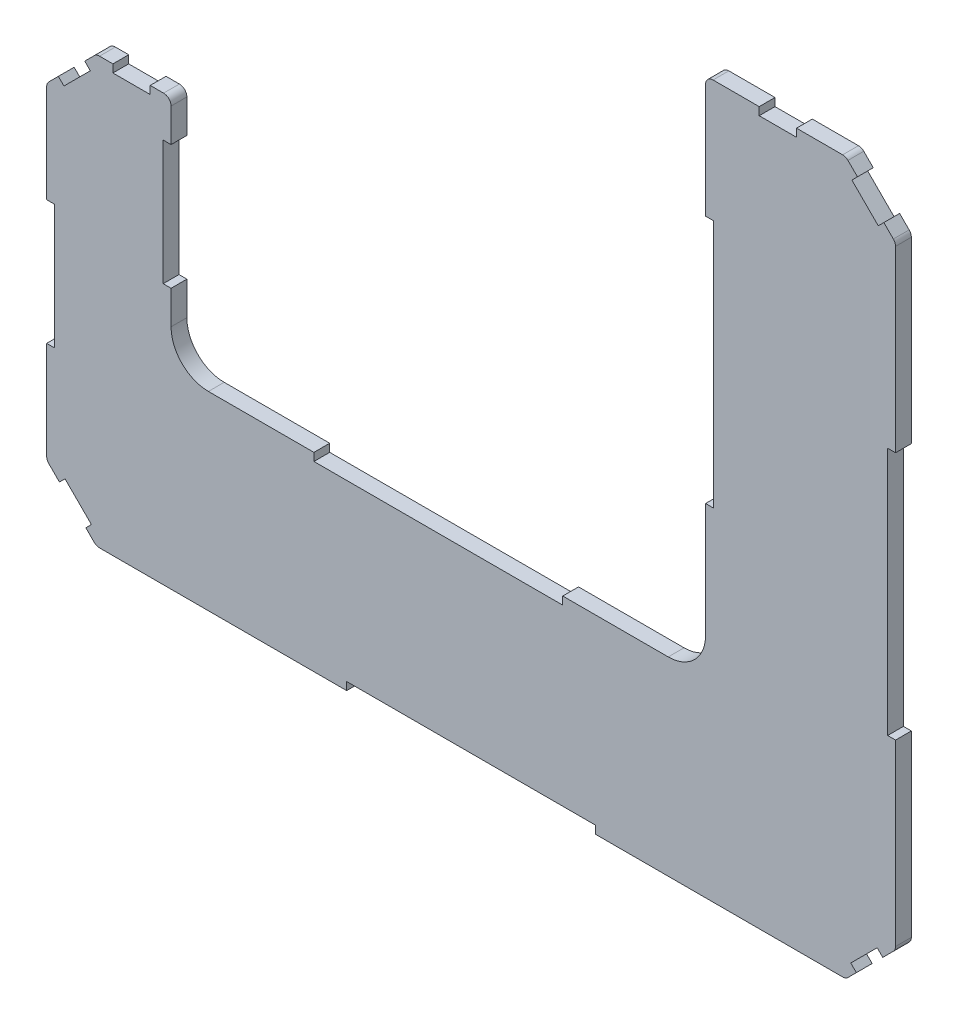
from build123d import *

# Parameters (mm, degrees)
BOSS_EXTRUDE1_DEPTH      = 3.175
BOSS_EXTRUDE1_DEPTH_BACK = 3.175
CHAMFER1_SIZE            = 20
FILLET1_R                = 15
FILLET2_R                = 3
SKETCH4_W                = 3.175
SKETCH4_H                = 50
SKETCH4_W_2              = 15
SKETCH4_H_2              = 3.175
SKETCH4_W_3              = 100
SKETCH4_H_3              = 100
WALL_SLOTS_DEPTH         = 60
FILLET3_R                = 3


with BuildPart() as part:
    # Sketch2 → Boss-Extrude1 (new body, two sides)
    with BuildSketch(Plane.XY) as boss_extrude1_sk:
        Polygon((-157.4125, 94.825), (-107.4125, 94.825), (-107.4125, 0), (107.4125, 0), (107.4125, 209.825), (183.7625, 209.825), (183.7625, -76.35), (58.275, -76.35), (-31.925, -76.35), (-157.4125, -76.35), align=None)
    extrude(amount=BOSS_EXTRUDE1_DEPTH)
    extrude(boss_extrude1_sk.sketch, amount=-BOSS_EXTRUDE1_DEPTH_BACK)

    # Chamfer1
    chamfer1_edges = [part.edges().sort_by_distance(p)[0] for p in [
        (-157.4125, 94.825, 0),
        (183.7625, 209.825, 0),
        (183.7625, -76.35, 0),
        (-157.4125, -76.35, 0),
    ]]
    chamfer(chamfer1_edges, length=CHAMFER1_SIZE)

    # Fillet1
    fillet1_edges = [part.edges().sort_by_distance(p)[0] for p in [
        (-107.4125, 0, 0),
        (107.4125, 0, 0),
    ]]
    fillet(fillet1_edges, radius=FILLET1_R)

    # Fillet2
    fillet2_edges = [part.edges().sort_by_distance(p)[0] for p in [
        (-107.4125, 94.825, 0),
        (107.4125, 209.825, 0),
        (-157.4125, 74.825, 0),
        (-157.4125, -56.35, 0),
        (183.7625, 189.825, 0),
        (183.7625, -56.35, 0),
        (163.7625, 209.825, 0),
        (-137.4125, 94.825, 0),
    ]]
    fillet(fillet2_edges, radius=FILLET2_R)

    # Sketch4 → wall_slots (cut)
    with BuildSketch(Plane.XY.offset(3.175)):
        with Locations((-109, 53.4125)):
            Rectangle(SKETCH4_W, SKETCH4_H)
        with Locations((-123.291179656, 93.2375)):
            Rectangle(SKETCH4_W_2, SKETCH4_H_2)
        Polygon((-142.109199141, 90.128300859), (-152.715800859, 79.521699141), (-150.470736829, 77.276635111), (-139.864135111, 87.883236829), align=None)
        with Locations((-155.825, 9.2375)):
            Rectangle(SKETCH4_W, SKETCH4_H)
        Polygon((-150.031397, -59.240974939), (-152.276461031, -61.486038969), (-141.669859313, -72.092640687), (-139.424795283, -69.847576657), align=None)
        with Locations((13.175, -74.7625)):
            Rectangle(SKETCH4_W_3, SKETCH4_H_2)
        with Locations((0, -1.5875)):
            Rectangle(SKETCH4_W_3, SKETCH4_H_2)
        Polygon((165.774795283, -69.847576657), (168.019859313, -72.092640687), (173.323160172, -66.789339828), (171.078096142, -64.544275798), align=None)
        Polygon((171.078096142, -64.544275798), (173.323160172, -66.789339828), (178.626461031, -61.486038969), (176.381397, -59.240974939), align=None)
        with Locations((182.175, 66.7375)):
            Rectangle(SKETCH4_W, SKETCH4_H_3)
        with Locations((109, 110.9125)):
            Rectangle(SKETCH4_W, SKETCH4_H_3)
        with Locations((136.466179656, 208.2375)):
            Rectangle(SKETCH4_W_2, SKETCH4_H_2)
        Polygon((179.065800859, 194.521699141), (168.459199141, 205.128300859), (166.214135111, 202.883236829), (176.820736829, 192.276635111), align=None)
    extrude(amount=-WALL_SLOTS_DEPTH, mode=Mode.SUBTRACT)

    # Fillet3
    fillet3_edges = [part.edges().sort_by_distance(p)[0] for p in [
        (163.7625, -76.35, 0),
        (-137.4125, -76.35, 0),
    ]]
    fillet(fillet3_edges, radius=FILLET3_R)


solid = part.part
